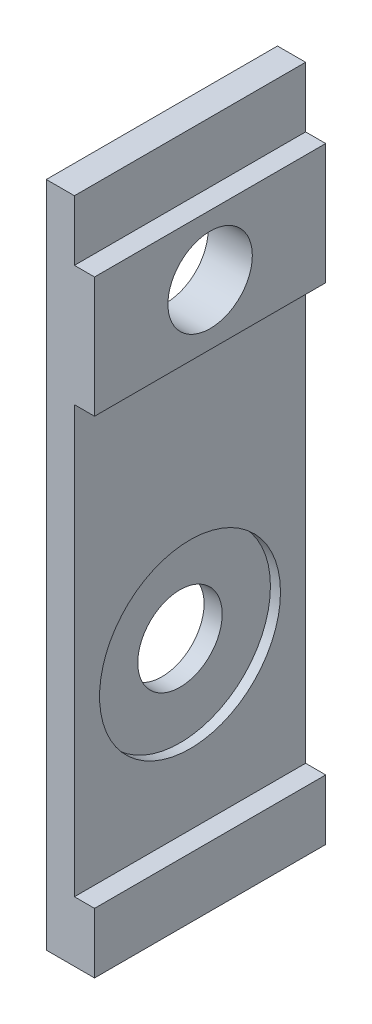
from build123d import *

# Parameters (mm, degrees)
SALIENTE_EXTRUIR1_DEPTH = 11.5
CORTAR_EXTRUIR1_START   = -2.4
CROQUIS2_R              = 2.1
CORTAR_EXTRUIR1_DEPTH   = 2.4
CROQUIS3_R              = 4.5
CORTAR_EXTRUIR2_DEPTH   = 0.5
CROQUIS4_R              = 3
CORTAR_EXTRUIR3_DEPTH   = 0.2


with BuildPart() as part:
    # Croquis1 → Saliente-Extruir1 (new body)
    with BuildSketch(Plane.XY):
        Polygon((-89.253382482, -13.336480186), (-89.253382482, 19.863519814), (-87.853382482, 19.863519814), (-87.853382482, 16.863519814), (-86.853382482, 16.863519814), (-86.853382482, 10.863519814), (-87.853382482, 10.863519814), (-87.853382482, -10.336480186), (-86.853382482, -10.336480186), (-86.853382482, -13.336480186), align=None)
    extrude(amount=SALIENTE_EXTRUIR1_DEPTH)

    # Croquis2 → Cortar-Extruir1 (cut)
    with BuildSketch(Plane(origin=(-86.853382482, 0, 0), x_dir=(0, 0, -1), z_dir=(1, 0, 0)).offset(CORTAR_EXTRUIR1_START)):
        with Locations((-5.75, 13.863519814)):
            Circle(CROQUIS2_R)
        with Locations((-5.75, -2.336480186)):
            Circle(CROQUIS2_R)
    extrude(amount=CORTAR_EXTRUIR1_DEPTH, mode=Mode.SUBTRACT)

    # Croquis3 → Cortar-Extruir2 (cut)
    with BuildSketch(Plane(origin=(-87.853382482, 0, 0), x_dir=(0, 0, -1), z_dir=(1, 0, 0))):
        with Locations((-5.75, -2.336480186)):
            Circle(CROQUIS3_R)
    extrude(amount=-CORTAR_EXTRUIR2_DEPTH, mode=Mode.SUBTRACT)

    # Croquis4 → Cortar-Extruir3 (cut)
    with BuildSketch(Plane.ZY.offset(89.253382482)):
        with Locations((5.75, 13.863519814)):
            Circle(CROQUIS4_R)
    extrude(amount=-CORTAR_EXTRUIR3_DEPTH, mode=Mode.SUBTRACT)


solid = part.part
